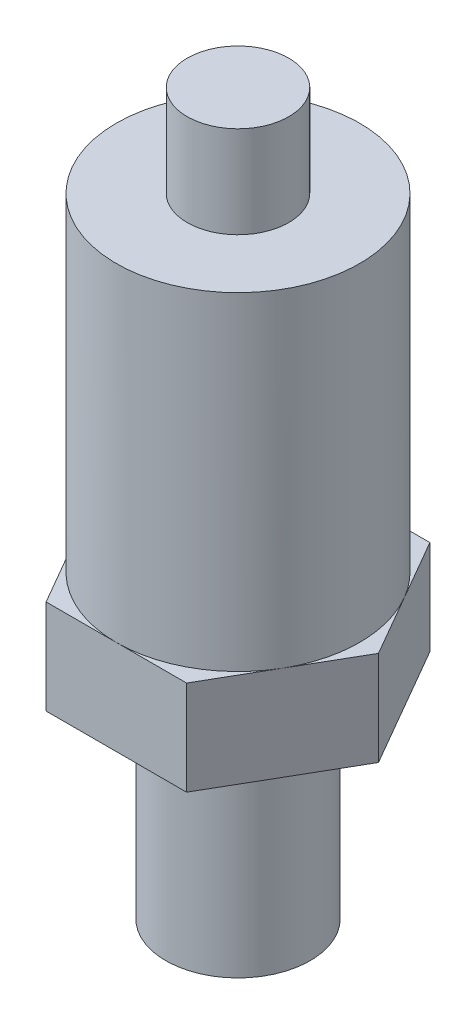
from build123d import *

# Parameters (mm, degrees)
BOSS_EXTRUDE1_DEPTH = 8.636


with BuildPart() as part:
    # Sketch1 → Revolve1 (revolve)
    with BuildSketch(Plane.XY):
        Polygon((0, 0), (0, 29.972), (6.477, 29.972), (6.477, 38.354), (11.1125, 38.354), (11.1125, 0), (11.1125, -27.432), (4.5125, -27.432), (4.5125, -8.636), (0, -8.636), align=None)
    revolve(axis=Axis((11.1125, 38.354, 0), (0, -1, 0)))

    # Sketch2 → Boss-Extrude1 (add)
    with BuildSketch(Plane.XZ.offset(8.636)):
        Polygon((23.944109733, 0), (17.528304866, 11.1125), (4.696695134, 11.1125), (-1.719109733, 0), (4.696695134, -11.1125), (17.528304866, -11.1125), align=None)
    extrude(amount=-BOSS_EXTRUDE1_DEPTH)


solid = part.part
